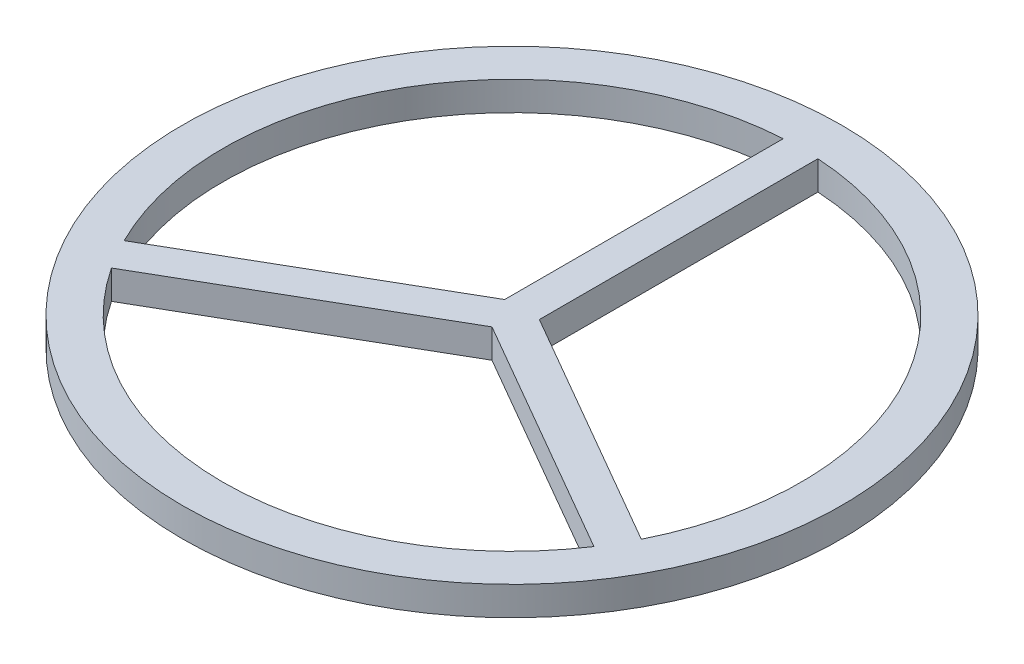
from build123d import *

# Parameters (mm, degrees)
SKETCH1_R           = 28.5
SKETCH1_R_2         = 25
BOSS_EXTRUDE1_DEPTH = 2.5
BOSS_EXTRUDE2_DEPTH = 2.5


with BuildPart() as part:
    # Sketch1 → Boss-Extrude1 (new body)
    with BuildSketch(Plane(origin=(0, 0, 0), x_dir=(1, 0, 0), z_dir=(0, 1, 0))):
        Circle(SKETCH1_R)
        Circle(SKETCH1_R_2, mode=Mode.SUBTRACT)
    extrude(amount=BOSS_EXTRUDE1_DEPTH)

    # Sketch2 → Boss-Extrude2 (add)
    with BuildSketch(Plane(origin=(0, 2.5, 0), x_dir=(1, 0, 0), z_dir=(0, 1, 0))):
        Polygon((-1.5, 0.866025404), (-22.400635095, -11.200961894), (-20.900635095, -13.799038106), (0, -1.732050808), (20.900635095, -13.799038106), (22.400635095, -11.200961894), (1.5, 0.866025404), (1.5, 25), (-1.5, 25), align=None)
    extrude(amount=-BOSS_EXTRUDE2_DEPTH)


solid = part.part
